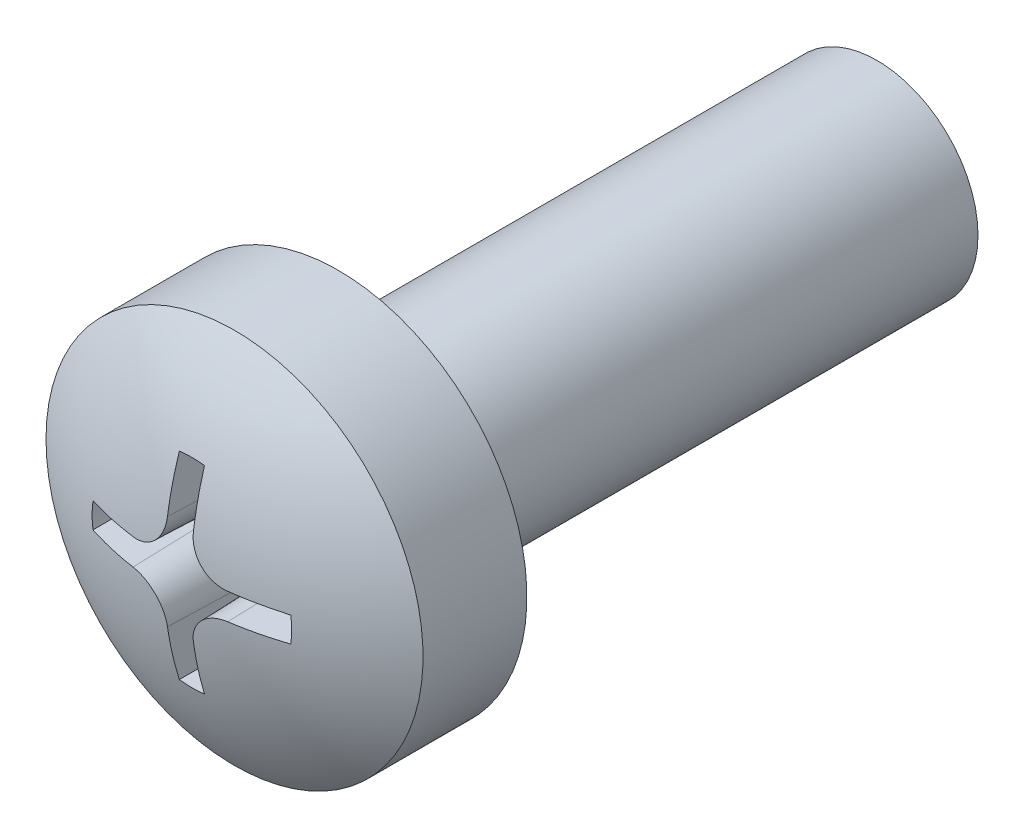
from build123d import *

# Parameters (mm, degrees)
SKETCH1_R          = 1.5
BASE_EXTRUDE_DEPTH = 8
CUT_EXTRUDE1_DEPTH = 1.799999969
CUT_EXTRUDE1_TAPER = 2


with BuildPart() as part:
    # Sketch1 → Base-Extrude (new body)
    with BuildSketch(Plane.XY):
        Circle(SKETCH1_R)
    extrude(amount=BASE_EXTRUDE_DEPTH)

    # Sketch6 → Boss-Revolve2 (revolve)
    with BuildSketch(Plane(origin=(0, 0, 0), x_dir=(1, 0, 0), z_dir=(0, 1, 0))):
        with BuildLine():
            Line((0, -8), (2.7999999, -8))
            Line((2.7999999, -8), (2.7999999, -9.54246308))
            ThreePointArc((2.7999999, -9.54246308), (1.46418655, -10.180811406), (0, -10.4))
            Line((0, -10.4), (0, -8))
        make_face()
    revolve(axis=Axis((0, 0, -0.393620135), (0, 0, 1)))

    # Sketch7 → Cut-Extrude1 (cut)
    with BuildSketch(Plane(origin=(0, 0, 10.7000001), x_dir=(-1, 0, 0), z_dir=(0, 0, -1))):
        with BuildLine():
            ThreePointArc((0.205000004, 1.48592565), (0, 1.500000013), (-0.205000004, 1.48592565))
            Line((-0.205000004, 1.48592565), (-0.205000004, 0.708178558))
            ThreePointArc((-0.205000004, 0.708178558), (-0.35072876, 0.355344481), (-0.702967546, 0.208182689))
            Line((-0.702967546, 0.208182689), (-1.48592565, 0.205000004))
            ThreePointArc((-1.48592565, 0.205000004), (-1.500000013, 0), (-1.48592565, -0.205000004))
            Line((-1.48592565, -0.205000004), (-0.702967546, -0.208182689))
            ThreePointArc((-0.702967546, -0.208182689), (-0.35072876, -0.355344481), (-0.205000004, -0.708178558))
            Line((-0.205000004, -0.708178558), (-0.205000004, -1.48592565))
            ThreePointArc((-0.205000004, -1.48592565), (0, -1.500000013), (0.205000004, -1.48592565))
            Line((0.205000004, -1.48592565), (0.205000004, -0.708178558))
            ThreePointArc((0.205000004, -0.708178558), (0.35072876, -0.355344481), (0.702967546, -0.208182689))
            Line((0.702967546, -0.208182689), (1.48592565, -0.205000004))
            ThreePointArc((1.48592565, -0.205000004), (1.500000013, 0), (1.48592565, 0.205000004))
            Line((1.48592565, 0.205000004), (0.702967546, 0.208182689))
            ThreePointArc((0.702967546, 0.208182689), (0.35072876, 0.355344481), (0.205000004, 0.708178558))
            Line((0.205000004, 0.708178558), (0.205000004, 1.48592565))
        make_face()
    extrude(amount=CUT_EXTRUDE1_DEPTH, taper=CUT_EXTRUDE1_TAPER, mode=Mode.SUBTRACT)


solid = part.part
